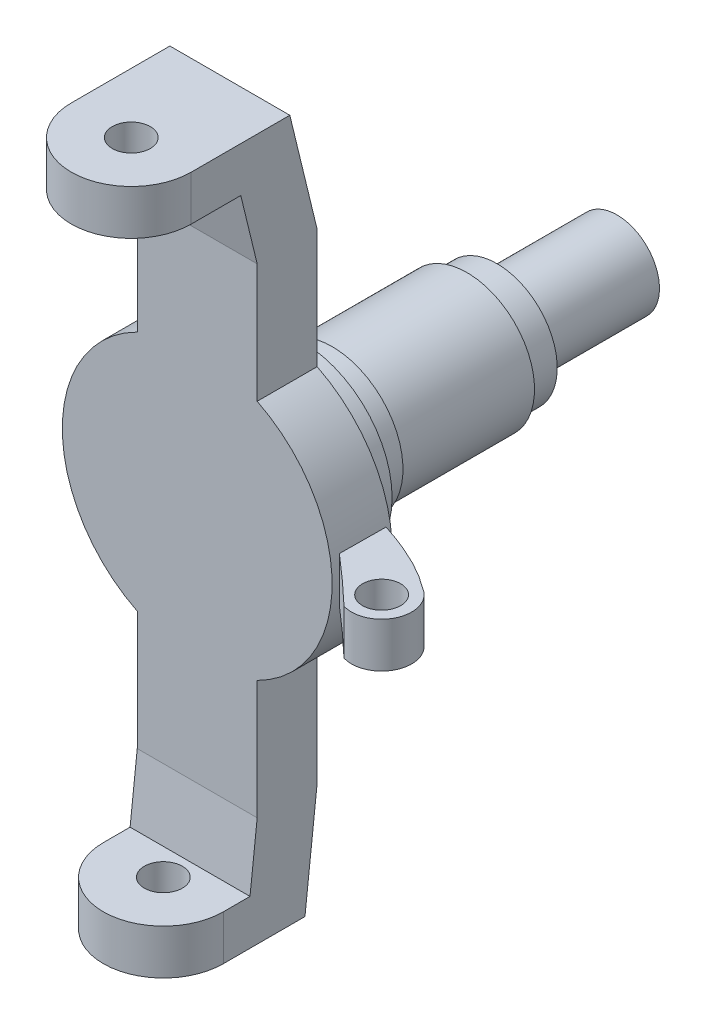
from build123d import *

# Parameters (mm, degrees)
BOSS_EXTRUDE1_DEPTH = 20
BOSS_EXTRUDE2_DEPTH = 20
CUT_EXTRUDE1_DEPTH  = 40
SKETCH3_R           = 6.35
CUT_EXTRUDE2_DEPTH  = 40
BOSS_EXTRUDE3_DEPTH = 20
SKETCH6_R           = 6.35
CUT_EXTRUDE4_DEPTH  = 40
SKETCH9_R           = 30
SKETCH9_R_2         = 23.625
BOSS_EXTRUDE4_DEPTH = 15
SKETCH9_3_R         = 23.625
SKETCH9_3_R_2       = 22.5
BOSS_EXTRUDE5_DEPTH = 25
SKETCH9_4_R         = 22.5
SKETCH9_4_R_2       = 20.075
BOSS_EXTRUDE6_DEPTH = 70
SKETCH9_5_R         = 20.075
SKETCH9_5_R_2       = 14.175
BOSS_EXTRUDE7_DEPTH = 80
SKETCH9_6_R         = 14.175
BOSS_EXTRUDE8_DEPTH = 120
CUT_EXTRUDE5_DEPTH  = 120
SKETCH12_R          = 6.35
BOSS_EXTRUDE9_DEPTH = 7.5


with BuildPart() as part:
    # Sketch1 → Boss-Extrude1 (new body)
    with BuildSketch(Plane.XY):
        with BuildLine():
            Line((20, 80), (-20, 80))
            Line((-20, 80), (-20, 40.311288741))
            ThreePointArc((-20, 40.311288741), (-45, 0), (-20, -40.311288741))
            Line((-20, -40.311288741), (-20, -80))
            Line((-20, -80), (20, -80))
            Line((20, -80), (20, -40.311288741))
            ThreePointArc((20, -40.311288741), (45, 0), (20, 40.311288741))
            Line((20, 40.311288741), (20, 80))
        make_face()
    extrude(amount=BOSS_EXTRUDE1_DEPTH)

    # Sketch2 → Boss-Extrude2 (add, symmetric)
    with BuildSketch(Plane(origin=(0, 0, 0), x_dir=(0, 0, -1), z_dir=(1, 0, 0))):
        Polygon((-20, 80), (0, 80), (-9.116936514, 117.5), (-63.916468616, 117.5), (-63.916468616, 102.5), (-25.470161908, 102.5), align=None)
    extrude(amount=BOSS_EXTRUDE2_DEPTH, both=True)

    # Sketch4 → Cut-Extrude1 (cut)
    with BuildSketch(Plane(origin=(0, 117.5, 0), x_dir=(1, 0, 0), z_dir=(0, 1, 0))):
        with BuildLine():
            Line((-20, -42), (-20, -63.916468616))
            Line((-20, -63.916468616), (20, -63.916468616))
            Line((20, -63.916468616), (20, -42))
            ThreePointArc((20, -42), (0, -62), (-20, -42))
        make_face()
    extrude(amount=-CUT_EXTRUDE1_DEPTH, mode=Mode.SUBTRACT)

    # Sketch3 → Cut-Extrude2 (cut)
    with BuildSketch(Plane(origin=(0, 117.5, 0), x_dir=(1, 0, 0), z_dir=(0, 1, 0))):
        with Locations((0, -42)):
            Circle(SKETCH3_R)
    extrude(amount=-CUT_EXTRUDE2_DEPTH, mode=Mode.SUBTRACT)

    # Sketch5 → Boss-Extrude3 (add, symmetric)
    with BuildSketch(Plane(origin=(0, 0, 0), x_dir=(0, 0, -1), z_dir=(1, 0, 0))):
        Polygon((-20, -80), (0, -80), (-4.065810475, -116.5), (-57.146175878, -116.5), (-57.146175878, -101.5), (-22.394929458, -101.5), align=None)
    extrude(amount=BOSS_EXTRUDE3_DEPTH, both=True)

    # Sketch6 → Cut-Extrude4 (cut)
    with BuildSketch(Plane.XZ.offset(116.5)):
        with Locations((0, 31.3)):
            Circle(SKETCH6_R)
    extrude(amount=-CUT_EXTRUDE4_DEPTH, mode=Mode.SUBTRACT)

    # Sketch9 → Boss-Extrude4 (add)
    with BuildSketch(Plane(origin=(0, 0, 0), x_dir=(-1, 0, 0), z_dir=(0, 0, -1))):
        Circle(SKETCH9_R)
        Circle(SKETCH9_R_2, mode=Mode.SUBTRACT)
    extrude(amount=BOSS_EXTRUDE4_DEPTH)

    # Sketch9_3 → Boss-Extrude5 (add)
    with BuildSketch(Plane(origin=(0, 0, 0), x_dir=(-1, 0, 0), z_dir=(0, 0, -1))):
        Circle(SKETCH9_3_R)
        Circle(SKETCH9_3_R_2, mode=Mode.SUBTRACT)
    extrude(amount=BOSS_EXTRUDE5_DEPTH)

    # Sketch9_4 → Boss-Extrude6 (add)
    with BuildSketch(Plane(origin=(0, 0, 0), x_dir=(-1, 0, 0), z_dir=(0, 0, -1))):
        Circle(SKETCH9_4_R)
        Circle(SKETCH9_4_R_2, mode=Mode.SUBTRACT)
    extrude(amount=BOSS_EXTRUDE6_DEPTH)

    # Sketch9_5 → Boss-Extrude7 (add)
    with BuildSketch(Plane(origin=(0, 0, 0), x_dir=(-1, 0, 0), z_dir=(0, 0, -1))):
        Circle(SKETCH9_5_R)
        Circle(SKETCH9_5_R_2, mode=Mode.SUBTRACT)
    extrude(amount=BOSS_EXTRUDE7_DEPTH)

    # Sketch9_6 → Boss-Extrude8 (add)
    with BuildSketch(Plane(origin=(0, 0, 0), x_dir=(-1, 0, 0), z_dir=(0, 0, -1))):
        Circle(SKETCH9_6_R)
    extrude(amount=BOSS_EXTRUDE8_DEPTH)

    # Sketch10 → Cut-Extrude5 (cut)
    with BuildSketch(Plane(origin=(0, -101.5, 0), x_dir=(1, 0, 0), z_dir=(0, 1, 0))):
        with BuildLine():
            Line((-20, -31.3), (-20, -57.146175878))
            Line((-20, -57.146175878), (20, -57.146175878))
            Line((20, -57.146175878), (20, -31.3))
            ThreePointArc((20, -31.3), (0, -51.3), (-20, -31.3))
        make_face()
    extrude(amount=-CUT_EXTRUDE5_DEPTH, mode=Mode.SUBTRACT)

    # Sketch12 → Boss-Extrude9 (add, symmetric)
    with BuildSketch(Plane(origin=(0, 0, 0), x_dir=(1, 0, 0), z_dir=(0, 1, 0))):
        with BuildLine():
            Line((45, -2.018705138), (44.876123934, -17.463703547))
            add(Edge.make_bspline(
                [(44.876123934, -17.463703547), (53.437219623, -24.801983569), (60.835955623, -31.879035395)],
                knots=[0, 0, 0, 1, 1, 1], degree=2))
            ThreePointArc((60.835955623, -31.879035395), (72.992020693, -26.306274296), (68.799253388, -13.607995414))
            add(Edge.make_bspline(
                [(45, -2.018705138), (59.856089875, -6.764812241), (68.799253388, -13.607995414)],
                knots=[0, 0, 0, 1, 1, 1], degree=2))
        make_face()
        with Locations((63.8, -22.3)):
            Circle(SKETCH12_R, mode=Mode.SUBTRACT)
    extrude(amount=BOSS_EXTRUDE9_DEPTH, both=True)


solid = part.part
